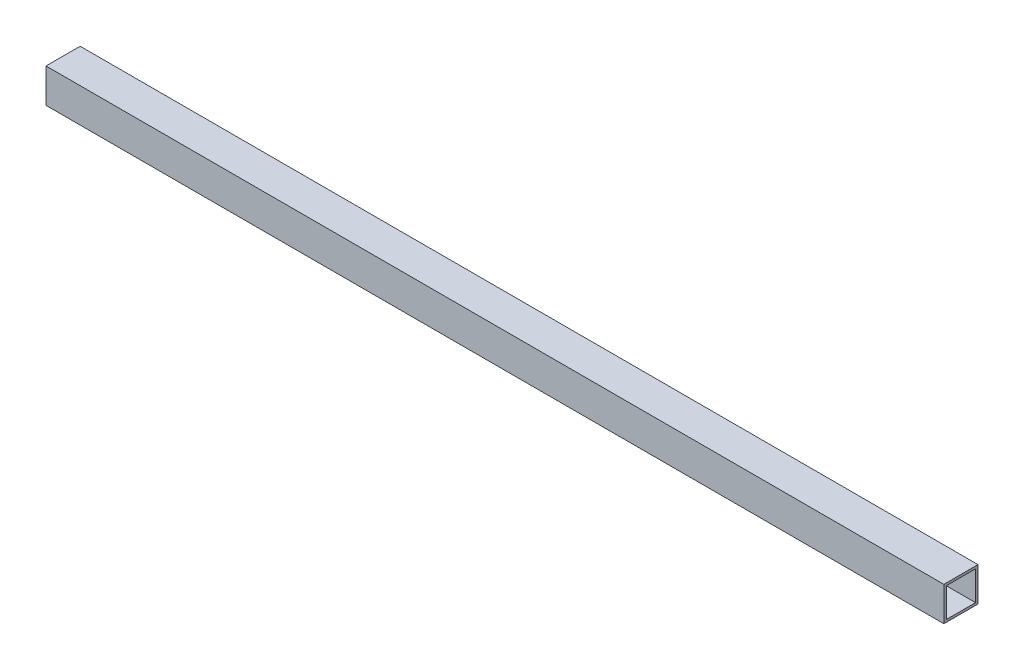
from build123d import *

# Parameters (mm, degrees)
SKETCH1_W           = 44.45
SKETCH1_H           = 44.45
SKETCH1_W_2         = 38.1
SKETCH1_H_2         = 38.1
BOSS_EXTRUDE1_DEPTH = 584.2


with BuildPart() as part:
    # Sketch1 → Boss-Extrude1 (new body, symmetric)
    with BuildSketch(Plane(origin=(0, 0, 0), x_dir=(0, 0, -1), z_dir=(1, 0, 0))):
        with Locations((22.225, 22.225)):
            Rectangle(SKETCH1_W, SKETCH1_H)
        with Locations((22.225, 22.225)):
            Rectangle(SKETCH1_W_2, SKETCH1_H_2, mode=Mode.SUBTRACT)
    extrude(amount=BOSS_EXTRUDE1_DEPTH, both=True)


solid = part.part
